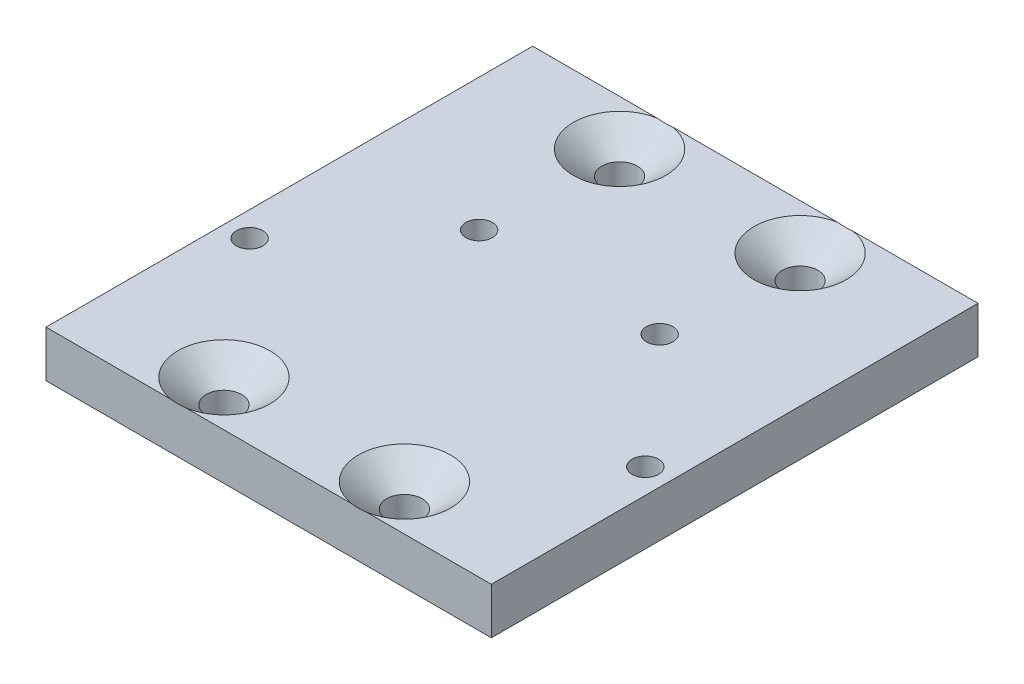
from build123d import *

# Parameters (mm, degrees)
SKETCH1_W                                         = 45.745826238
SKETCH1_H                                         = 49.9872
BOSS_EXTRUDE1_DEPTH                               = 4.7625
CSK_FOR_6_FLAT_HEAD_MACHINE_SCREW_100_D           = 3.6576
CSK_FOR_6_FLAT_HEAD_MACHINE_SCREW_100_CSINK_D     = 9.4701106
CSK_FOR_6_FLAT_HEAD_MACHINE_SCREW_100_CSINK_ANGLE = 100
SKETCH8_R                                         = 1.3589
CUT_EXTRUDE1_DEPTH                                = 3365.184229833


with BuildPart() as part:
    # Sketch1 → Boss-Extrude1 (new body)
    with BuildSketch(Plane(origin=(0, -2000, 0), x_dir=(1, 0, 0), z_dir=(0, 1, 0))):
        with Locations((-1550.959562055, 2948.348659299)):
            Rectangle(SKETCH1_W, SKETCH1_H)
    extrude(amount=BOSS_EXTRUDE1_DEPTH)

    # CSK for _6 Flat Head Machine Screw _100 (through all)
    with Locations(Plane(origin=(-1560.230562055, -1995.2375, -2968.668659299), x_dir=(0, 0, 1), z_dir=(0, 1, 0))):
        with Locations((0, 0), (40.64, 0), (40.64, 18.542), (0, 18.542)):
            CounterSinkHole(CSK_FOR_6_FLAT_HEAD_MACHINE_SCREW_100_D / 2, CSK_FOR_6_FLAT_HEAD_MACHINE_SCREW_100_CSINK_D / 2, counter_sink_angle=CSK_FOR_6_FLAT_HEAD_MACHINE_SCREW_100_CSINK_ANGLE)

    # Sketch8 → Cut-Extrude1 (cut, through all)
    with BuildSketch(Plane.XZ.offset(2000)):
        with Locations((-1541.684253717, -2954.236887357)):
            Circle(SKETCH8_R)
        with Locations((-1560.226253717, -2954.236887357)):
            Circle(SKETCH8_R)
        with Locations((-1571.277192756, -2941.714687357)):
            Circle(SKETCH8_R)
        with Locations((-1530.633314678, -2941.714687357)):
            Circle(SKETCH8_R)
    extrude(amount=-CUT_EXTRUDE1_DEPTH, mode=Mode.SUBTRACT)


solid = part.part
